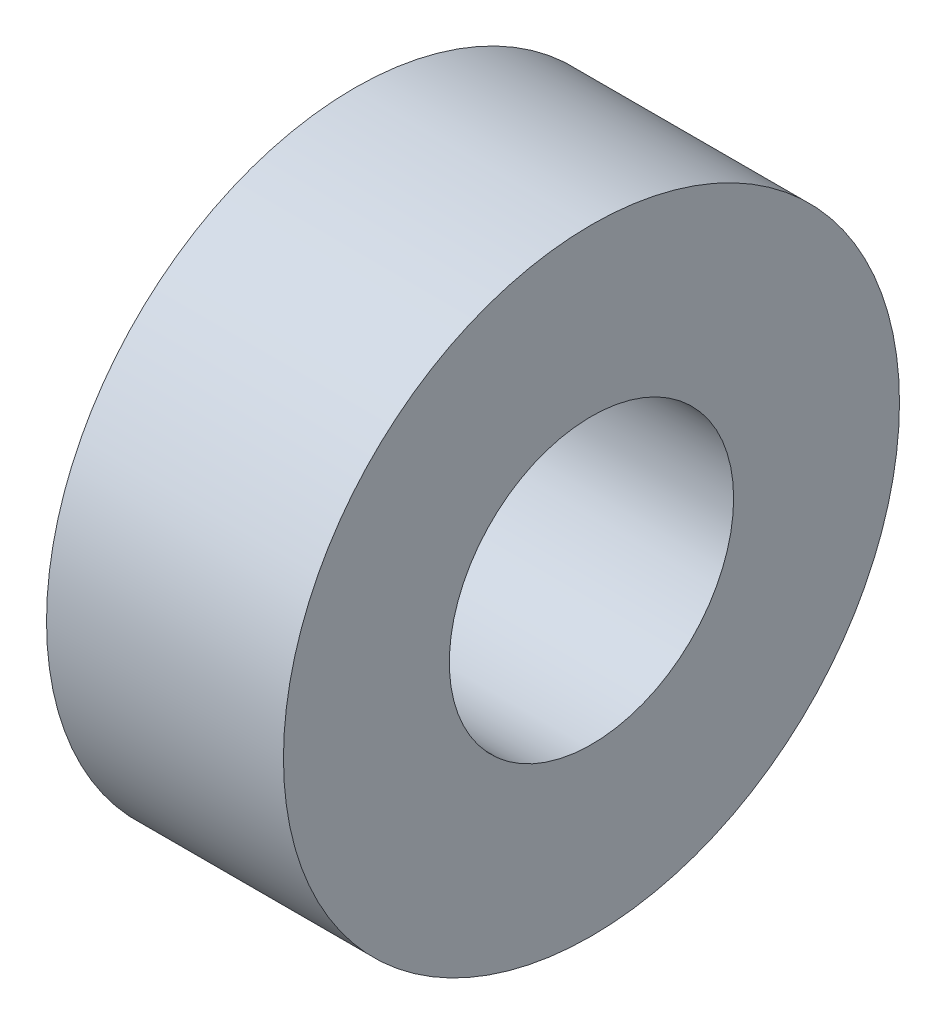
from build123d import *

# Parameters (mm, degrees)
SKETCH_1_R      = 6.5
SKETCH_1_R_2    = 3
EXTRUDE_1_DEPTH = 5


with BuildPart() as part:
    # 草图1 → 凸台-拉伸1 (new body)
    with BuildSketch(Plane(origin=(0, 0, 0), x_dir=(0, 0, -1), z_dir=(1, 0, 0))):
        Circle(SKETCH_1_R)
        Circle(SKETCH_1_R_2, mode=Mode.SUBTRACT)
    extrude(amount=EXTRUDE_1_DEPTH)


solid = part.part
